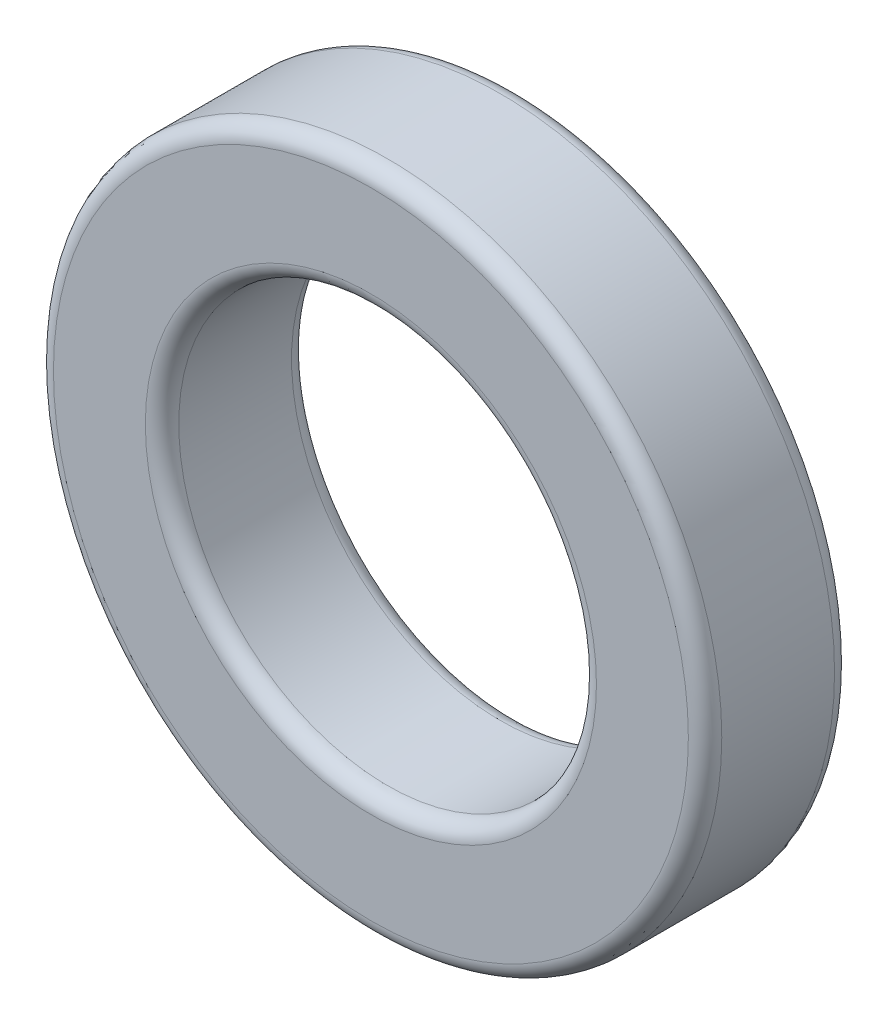
from build123d import *

# Parameters (mm, degrees)
SKETCH1_R           = 16
SKETCH1_R_2         = 10
BOSS_EXTRUDE1_DEPTH = 7
FILLET1_R           = 0.8


with BuildPart() as part:
    # Sketch1 → Boss-Extrude1 (new body)
    with BuildSketch(Plane.XY):
        Circle(SKETCH1_R)
        Circle(SKETCH1_R_2, mode=Mode.SUBTRACT)
    extrude(amount=BOSS_EXTRUDE1_DEPTH)

    # Fillet1
    fillet1_edges = [part.edges().sort_by_distance(p)[0] for p in [
        (-16, 0, 0),
        (-16, 0, 7),
        (-10, 0, 0),
        (-10, 0, 7),
    ]]
    fillet(fillet1_edges, radius=FILLET1_R)


solid = part.part
